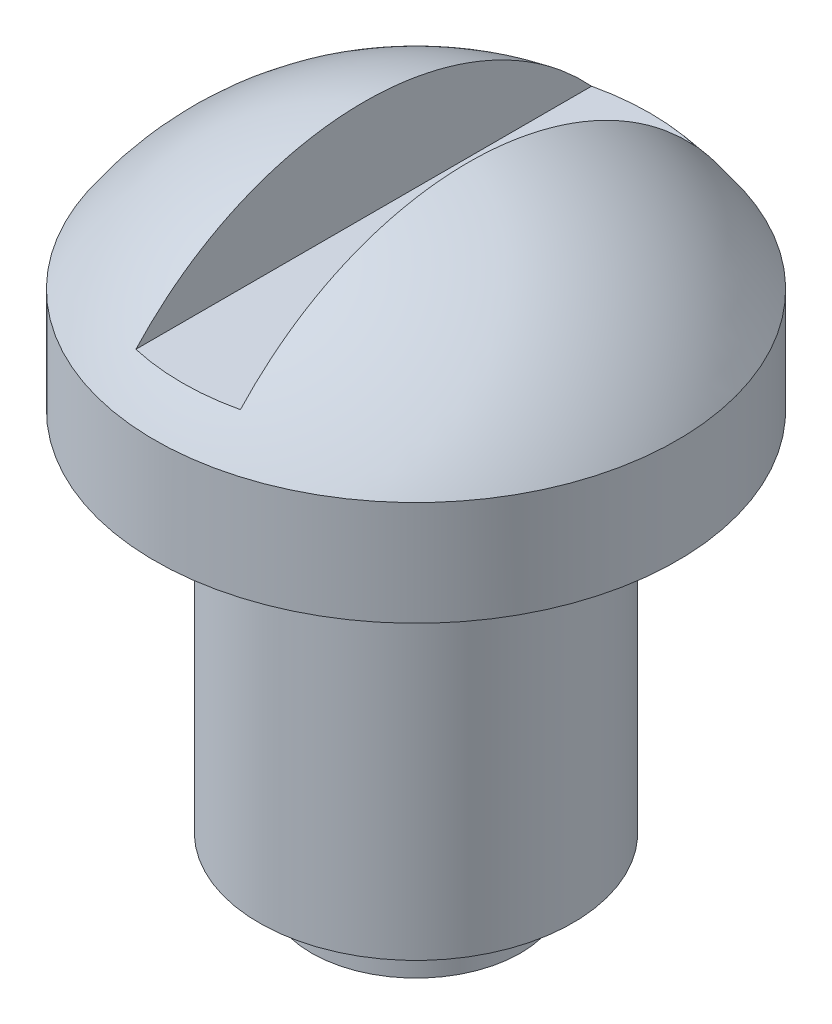
from build123d import *

# Parameters (mm, degrees)
SKETCH2_W               = 2
SKETCH2_H               = 3
CUT_EXTRUDE1_DEPTH      = 6
CUT_EXTRUDE1_DEPTH_BACK = 6


with BuildPart() as part:
    # Sketch1 → Revolve1 (revolve)
    with BuildSketch(Plane.XY):
        with BuildLine():
            Line((0, 12.68337521), (0, 0))
            Line((0, 0), (2, 0))
            Line((2, 0), (2, 1))
            Line((2, 1), (3, 1))
            Line((3, 1), (3, 8))
            Line((3, 8), (5, 8))
            Line((5, 8), (5, 10))
            ThreePointArc((5, 10), (2.837274331, 11.970139283), (0, 12.68337521))
        make_face()
    revolve(axis=Axis((0, 15.248921205, 0), (0, -1, 0)))

    # Sketch2 → Cut-Extrude1 (cut, two sides)
    with BuildSketch(Plane.XY) as cut_extrude1_sk:
        with Locations((0, 12.18337521)):
            Rectangle(SKETCH2_W, SKETCH2_H)
    extrude(amount=CUT_EXTRUDE1_DEPTH, mode=Mode.SUBTRACT)
    extrude(cut_extrude1_sk.sketch, amount=-CUT_EXTRUDE1_DEPTH_BACK, mode=Mode.SUBTRACT)


solid = part.part
